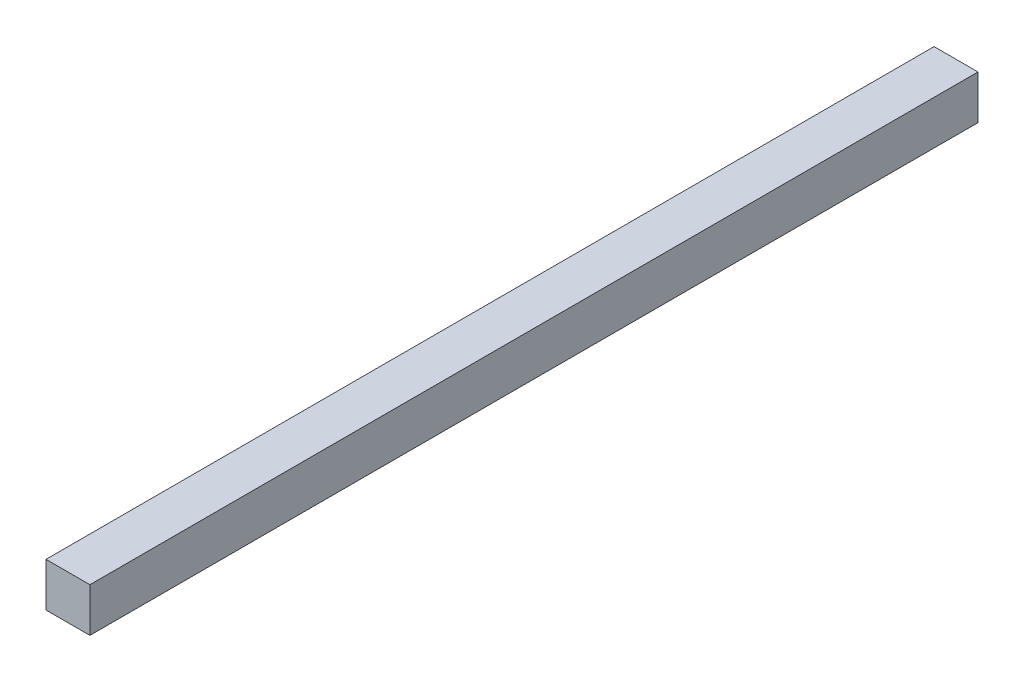
from build123d import *

# Parameters (mm, degrees)
SKETCH1_W           = 45
SKETCH1_H           = 45
BOSS_EXTRUDE1_DEPTH = 910


with BuildPart() as part:
    # Sketch1 → Boss-Extrude1 (new body)
    with BuildSketch(Plane.XY):
        with Locations((22.5, 22.5)):
            Rectangle(SKETCH1_W, SKETCH1_H)
    extrude(amount=BOSS_EXTRUDE1_DEPTH)


solid = part.part
